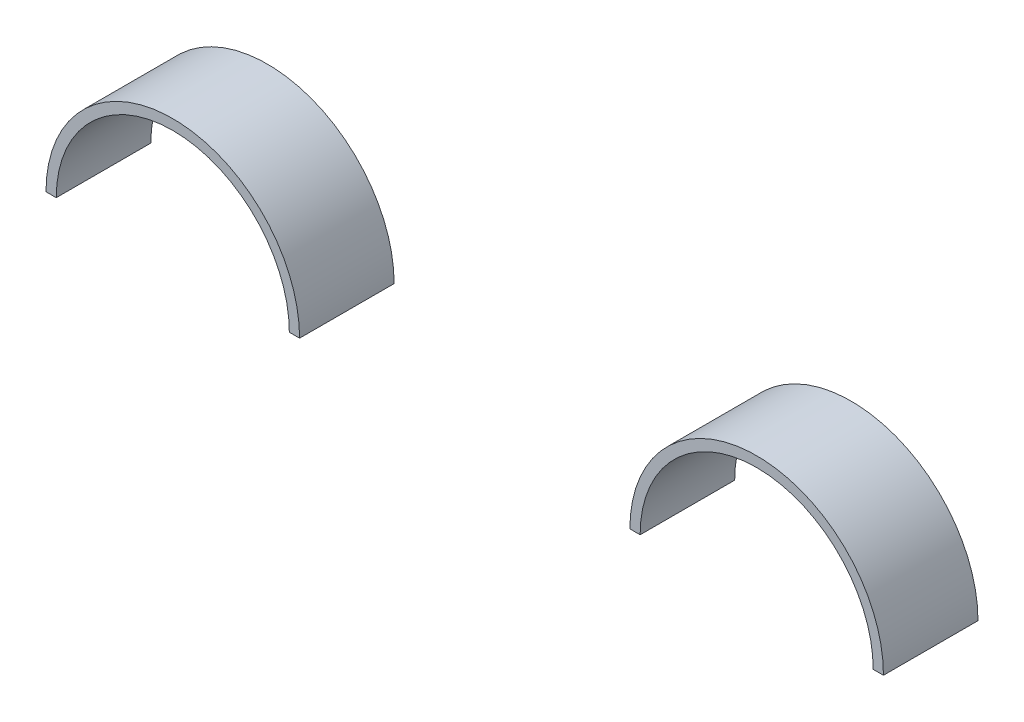
from build123d import *

# Parameters (mm, degrees)
BOSS_EXTRUDE1_DEPTH   = 40.56
BOSS_EXTRUDE1_2_DEPTH = 40.56


with BuildPart() as part:
    # Sketch1 → Boss-Extrude1 (new body)
    with BuildSketch(Plane(origin=(0, 0, 563.242336202), x_dir=(0, -1, 0), z_dir=(0, 0, -1))):
        with BuildLine():
            Line((326.790615215, -1394.880472759), (326.790615215, -1399.280472759))
            ThreePointArc((326.790615215, -1399.280472759), (276.790615215, -1449.280472759), (326.790615215, -1499.280472759))
            Line((326.790615215, -1499.280472759), (326.790615215, -1503.680472759))
            ThreePointArc((326.790615215, -1503.680472759), (272.390615215, -1449.280472759), (326.790615215, -1394.880472759))
        make_face()
    extrude(amount=BOSS_EXTRUDE1_DEPTH)


with BuildPart() as body_2:
    # Sketch1 → Boss-Extrude1 2 (new body)
    with BuildSketch(Plane(origin=(0, 0, 563.242336202), x_dir=(0, -1, 0), z_dir=(0, 0, -1))):
        with BuildLine():
            Line((326.790615215, -1749.780472759), (326.790615215, -1754.180472759))
            ThreePointArc((326.790615215, -1754.180472759), (272.390615215, -1699.780472759), (326.790615215, -1645.380472759))
            Line((326.790615215, -1645.380472759), (326.790615215, -1649.780472759))
            ThreePointArc((326.790615215, -1649.780472759), (276.790615215, -1699.780472759), (326.790615215, -1749.780472759))
        make_face()
    extrude(amount=BOSS_EXTRUDE1_2_DEPTH)


solid = Compound([part.part, body_2.part])
